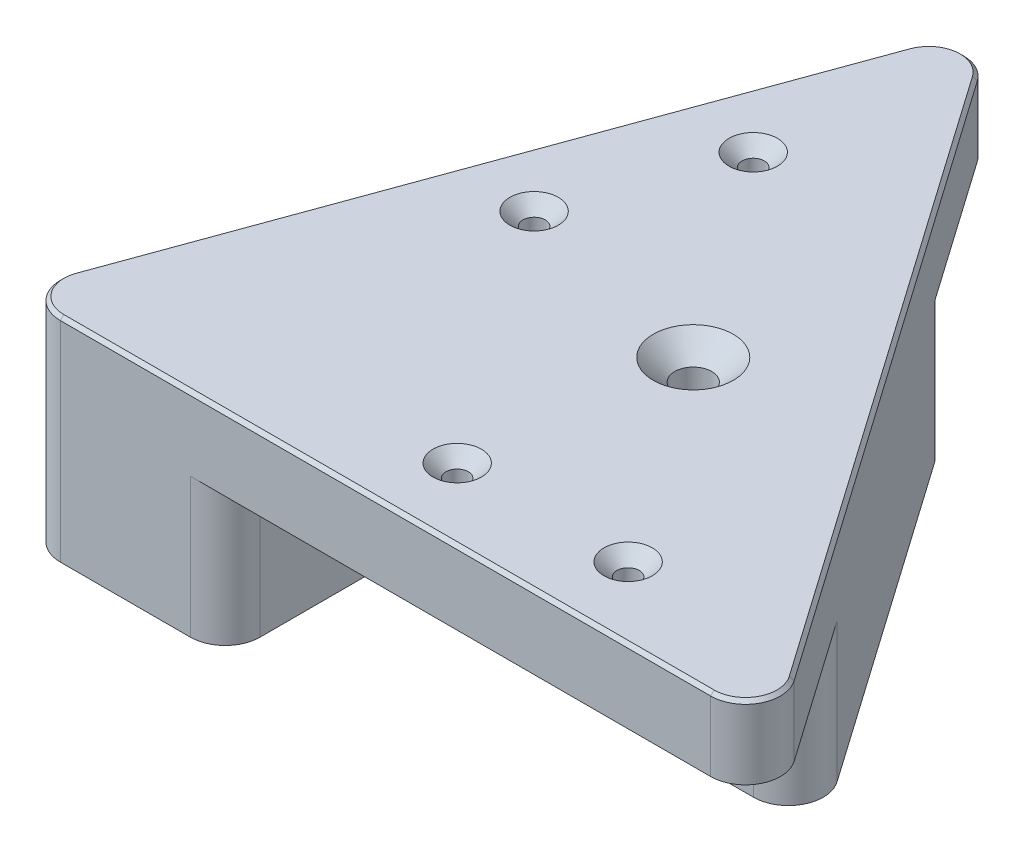
from build123d import *

# Parameters (mm, degrees)
SKETCH1_R                                            = 1.0000000000000033
SKETCH1_R_2                                          = 0.9999999999999979
SKETCH1_R_3                                          = 1.000000000000005
SKETCH1_R_4                                          = 1.0000000000000018
SKETCH1_R_5                                          = 1.0000000000000029
MAIN_BODY_DEPTH                                      = 10.5
PROFILE_STOPS_DEPTH                                  = 20
CSK_FOR_M3_HEX_SOCKET_COUNTERSUNK_HEAD_S_D           = 3.2
CSK_FOR_M3_HEX_SOCKET_COUNTERSUNK_HEAD_S_DEPTH       = 30.5
CSK_FOR_M3_HEX_SOCKET_COUNTERSUNK_HEAD_S_CSINK_D     = 6.94
CSK_FOR_M3_HEX_SOCKET_COUNTERSUNK_HEAD_S_CSINK_ANGLE = 90
CSK_FOR_M5_HEX_SOCKET_COUNTERSUNK_HEAD_S_D           = 5.3
CSK_FOR_M5_HEX_SOCKET_COUNTERSUNK_HEAD_S_DEPTH       = 30.5
CSK_FOR_M5_HEX_SOCKET_COUNTERSUNK_HEAD_S_CSINK_D     = 11.47
CSK_FOR_M5_HEX_SOCKET_COUNTERSUNK_HEAD_S_CSINK_ANGLE = 90
FILLET1_R                                            = 5
FILLET3_R                                            = 5
DRAFT1_ANGLE                                         = 0.5000000000000011
CHAMFER2_SIZE                                        = 0.5


with BuildPart() as part:
    # Sketch1 → Main Body (new body)
    with BuildSketch(Plane(origin=(0, 0, 0), x_dir=(1, 0, 0), z_dir=(0, 1, 0))):
        Polygon((-55, 0), (55, -6.74e-15), (-17.37778423417673, 103.36618828645003), align=None)
        with Locations(Location((-1.2076863300743388, 10.249999999999998, 0), (0, 0, 90))):
            Circle(SKETCH1_R, mode=Mode.SUBTRACT)
        with Locations(Location((23.307593201638067, 10.25, 0), (0, 0, 90))):
            Circle(SKETCH1_R_2, mode=Mode.SUBTRACT)
        with Locations(Location((-26.970095805737262, 47.04253374154206, 0), (0, 0, 90))):
            Circle(SKETCH1_R_3, mode=Mode.SUBTRACT)
        with Locations(Location((-18.585376386632234, 70.07936101399606, 0), (0, 0, 90))):
            Circle(SKETCH1_R_4, mode=Mode.SUBTRACT)
        with Locations(Location((2.578216537695586, 40.31670125636554, 0), (0, 0, 90))):
            Circle(SKETCH1_R_5, mode=Mode.SUBTRACT)
    extrude(amount=MAIN_BODY_DEPTH)

    # Sketch1_3 → Profile Stops (add)
    with BuildSketch(Plane(origin=(0, 0, 0), x_dir=(1, 0, 0), z_dir=(0, 1, 0))):
        Polygon((-55, 0), (-24.222965861786736, 0), (-24.22296586178674, 20.499999999999996), (40.64574546670092, 20.500000000000004), (-3.023529700877628, 82.86618828645001), (-25.209935646798243, 21.909538931178865), (-44.47363437290938, 28.920951869355026), align=None)
        Polygon((-7.671783462304414, 33.139573989716), (-10.559339294448062, 34.19055836239805), (-7.671783462304414, 42.1240528086273), (-7.6717834623044165, 50.56670125636553), (-4.598910728953966, 50.56670125636553), (-3.547926356271911, 53.45425708850919), (4.385568089957344, 50.56670125636554), (12.828216537695583, 50.56670125636554), (12.828216537695583, 47.49382852301509), (15.715772369839232, 46.44284415033304), (12.828216537695585, 38.5093497041038), (12.828216537695587, 30.066701256365544), (9.755343804345129, 30.066701256365544), (8.70435943166308, 27.1791454242219), (0.7708649854338496, 30.06670125636554), (-7.671783462304413, 30.06670125636554), align=None, mode=Mode.SUBTRACT)
    extrude(amount=-PROFILE_STOPS_DEPTH)

    # CSK for M3 Hex Socket Countersunk Head S
    with Locations(Plane(origin=(-18.585376387, 10.5, -70.079361014), x_dir=(0, 0, 1), z_dir=(0, 1, 0))):
        with Locations((0, 0), (23.036827272, -8.384719419), (59.829361014, 41.892969589), (59.829361014, 17.377690057)):
            CounterSinkHole(CSK_FOR_M3_HEX_SOCKET_COUNTERSUNK_HEAD_S_D / 2, CSK_FOR_M3_HEX_SOCKET_COUNTERSUNK_HEAD_S_CSINK_D / 2, depth=CSK_FOR_M3_HEX_SOCKET_COUNTERSUNK_HEAD_S_DEPTH, counter_sink_angle=CSK_FOR_M3_HEX_SOCKET_COUNTERSUNK_HEAD_S_CSINK_ANGLE)

    # CSK for M5 Hex Socket Countersunk Head S
    with Locations(Plane(origin=(2.578216538, 10.5, -40.316701256), x_dir=(0, 0, 1), z_dir=(0, 1, 0))):
        with Locations((0, 0)):
            CounterSinkHole(CSK_FOR_M5_HEX_SOCKET_COUNTERSUNK_HEAD_S_D / 2, CSK_FOR_M5_HEX_SOCKET_COUNTERSUNK_HEAD_S_CSINK_D / 2, depth=CSK_FOR_M5_HEX_SOCKET_COUNTERSUNK_HEAD_S_DEPTH, counter_sink_angle=CSK_FOR_M5_HEX_SOCKET_COUNTERSUNK_HEAD_S_CSINK_ANGLE)

    # Fillet1
    fillet1_edges = [part.edges().sort_by_distance(p)[0] for p in [
        (-55, -4.75, 0),
        (-24.222965861786736, -10, 0),
        (-44.47363437290938, -10, -28.920951869355026),
    ]]
    fillet(fillet1_edges, radius=FILLET1_R)

    # Fillet3
    fillet3_edges = [part.edges().sort_by_distance(p)[0] for p in [
        (55, 5.25, 6.74e-15),
        (-17.37778423417673, 5.25, -103.36618828645003),
        (-3.0235297008776296, -10, -82.86618828645001),
        (40.645745466700916, -10, -20.5),
    ]]
    fillet(fillet3_edges, radius=FILLET3_R)

    # Draft1
    draft1_faces = [part.faces().sort_by_distance(p)[0] for p in [
        (11.291780171020358, -10, -30.066701256365544),
        (9.229851618004107, -10, -28.62292334029372),
        (4.737612208548465, -10, -28.622923340293717),
        (-3.4504592384352817, -10, -30.06670125636554),
        (-7.671783462304413, -10.000000000000002, -31.60313762304077),
        (-9.115561378376238, -10, -33.665066176057024),
        (-9.115561378376238, -10, -38.157305585512674),
        (-6.135347095629191, -10, -50.56670125636553),
        (-7.671783462304415, -10, -46.345377032496415),
        (-4.073418542612939, -10, -52.010479172437364),
        (0.4188208668427172, -10, -52.010479172437364),
        (8.606892313826464, -10, -50.56670125636554),
        (12.828216537695583, -10, -49.030264889690315),
        (14.271994453767409, -10, -46.968336336674064),
        (14.271994453767409, -10, -42.476096927218414),
        (12.828216537695587, -10, -34.28802548023467),
    ]]
    draft(draft1_faces, Plane(origin=(0, 0, 0), x_dir=(0, 0, -1), z_dir=(0, -1, 0)), DRAFT1_ANGLE)

    # Chamfer2
    chamfer2_edges = [part.edges().sort_by_distance(p)[0] for p in [
        (-1.232085300572649, 10.5, 3.29e-15),
        (-36.61029010817967, 10.5, -50.52531267809811),
        (-51.95502018773441, 10.5, -2.1321178182447573),
        (18.811107882911628, 10.5, -51.683094143225006),
        (-16.61702500331109, 10.5, -97.58764822980864),
        (49.83014353103527, 10.5, -2.6912569338248247),
    ]]
    chamfer(chamfer2_edges, length=CHAMFER2_SIZE)


solid = part.part
